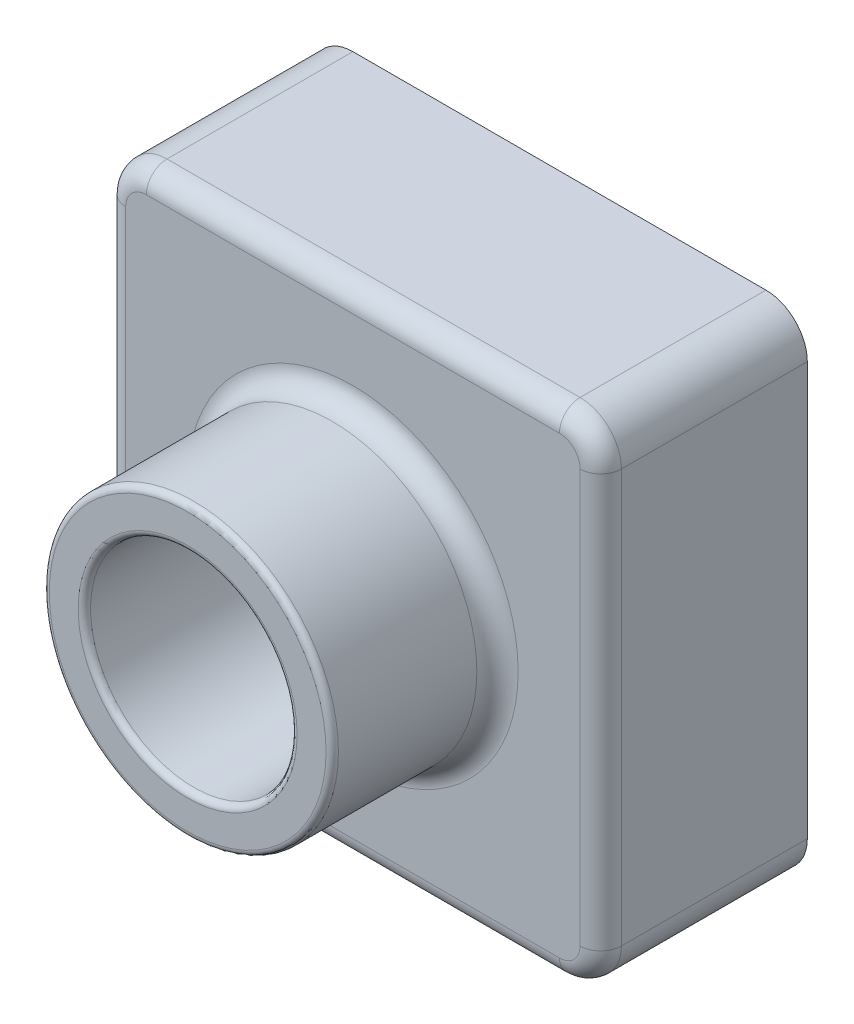
from build123d import *

# Parameters (mm, degrees)
SKETCH1_W           = 120
SKETCH1_H           = 120
BOSS_EXTRUDE1_DEPTH = 50
SKETCH2_R           = 35
BOSS_EXTRUDE2_DEPTH = 40
SKETCH3_R           = 25
CUT_EXTRUDE1_DEPTH  = 91
FILLET2_R           = 10
FILLET3_R           = 1.5
FILLET4_R           = 5
SHELL1_T            = -2


with BuildPart() as part:
    # Sketch1 → Boss-Extrude1 (new body)
    with BuildSketch(Plane.XY):
        with Locations((4.629080119, -31.513353116)):
            Rectangle(SKETCH1_W, SKETCH1_H)
    extrude(amount=BOSS_EXTRUDE1_DEPTH)

    # Sketch2 → Boss-Extrude2 (add)
    with BuildSketch(Plane.XY.offset(50)):
        with Locations((4.629080119, -31.513353116)):
            Circle(SKETCH2_R)
    extrude(amount=BOSS_EXTRUDE2_DEPTH)

    # Sketch3 → Cut-Extrude1 (cut, through all)
    with BuildSketch(Plane.XY.offset(90)):
        with Locations((4.629080119, -31.513353116)):
            Circle(SKETCH3_R)
    extrude(amount=-CUT_EXTRUDE1_DEPTH, mode=Mode.SUBTRACT)

    # Fillet2
    fillet2_edges = [part.edges().sort_by_distance(p)[0] for p in [
        (-55.370919881, 28.486646884, 25),
        (64.629080119, 28.486646884, 25),
        (64.629080119, -91.513353116, 25),
        (-55.370919881, -91.513353116, 25),
    ]]
    fillet(fillet2_edges, radius=FILLET2_R)

    # Fillet3
    fillet3_edges = [part.edges().sort_by_distance(p)[0] for p in [
        (-30.370919881, -31.513353116, 90),
        (-20.370919881, -31.513353116, 90),
    ]]
    fillet(fillet3_edges, radius=FILLET3_R)

    # Fillet4
    fillet4_edges = [part.edges().sort_by_distance(p)[0] for p in [
        (-30.370919881, -31.513353116, 50),
        (4.629080119, -91.513353116, 50),
        (-55.370919881, -31.513353116, 50),
        (64.629080119, -31.513353116, 50),
        (4.629080119, 28.486646884, 50),
        (61.700147931, 25.557714696, 50),
        (-52.441987693, 25.557714696, 50),
        (61.700147931, -88.584420928, 50),
        (-52.441987693, -88.584420928, 50),
    ]]
    fillet(fillet4_edges, radius=FILLET4_R)

    # Shell1
    shell1_openings = [part.faces().sort_by_distance(p)[0] for p in [
        (29.629080119, -31.513353116, 0),
    ]]
    offset(amount=SHELL1_T, openings=shell1_openings, kind=Kind.INTERSECTION)


solid = part.part
